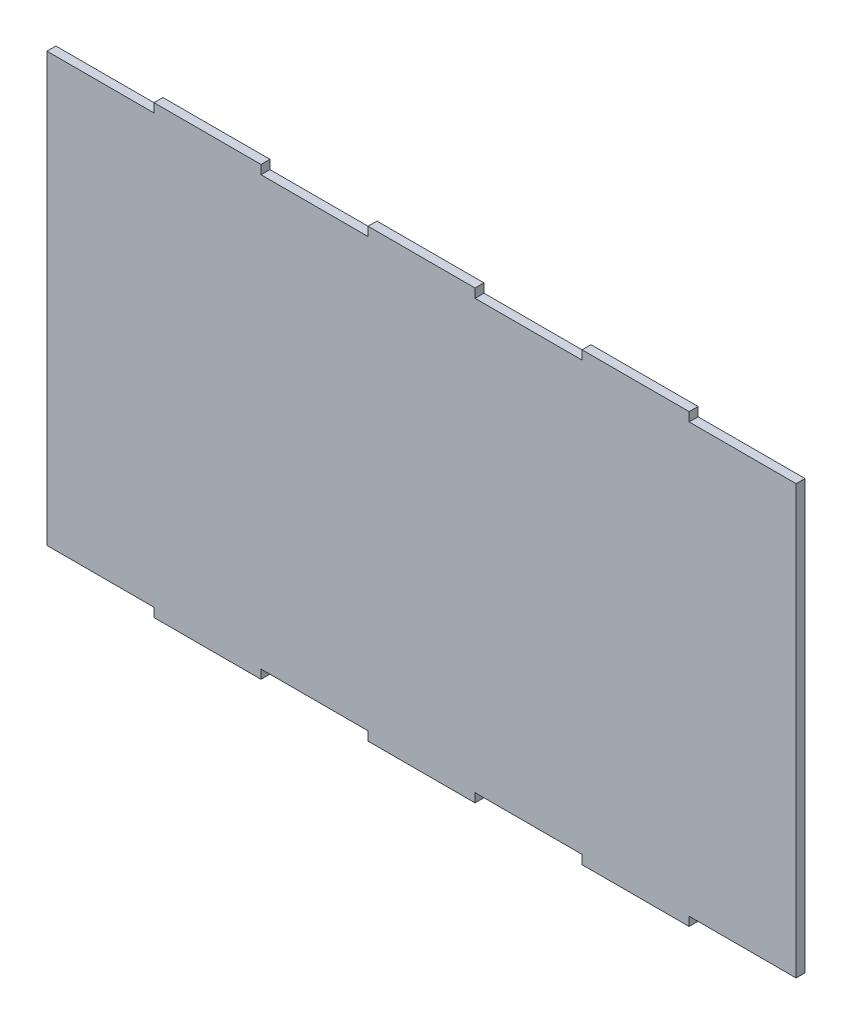
from build123d import *

# Parameters (mm, degrees)
BOSS_EXTRU_1_DEPTH = 5


with BuildPart() as part:
    # Esquisse1 → Boss.-Extru.1 (new body)
    with BuildSketch(Plane.XY):
        Polygon((360, 0), (360, 5), (420, 5), (420, 245), (360, 245), (360, 250), (300, 250), (300, 245), (240, 245), (240, 250), (180, 250), (180, 245), (120, 245), (120, 250), (60, 250), (60, 245), (0, 245), (0, 5), (60, 5), (60, 0), (120, 0), (120, 5), (180, 5), (180, 0), (240, 0), (240, 5), (300, 5), (300, 0), align=None)
    extrude(amount=BOSS_EXTRU_1_DEPTH)


solid = part.part
